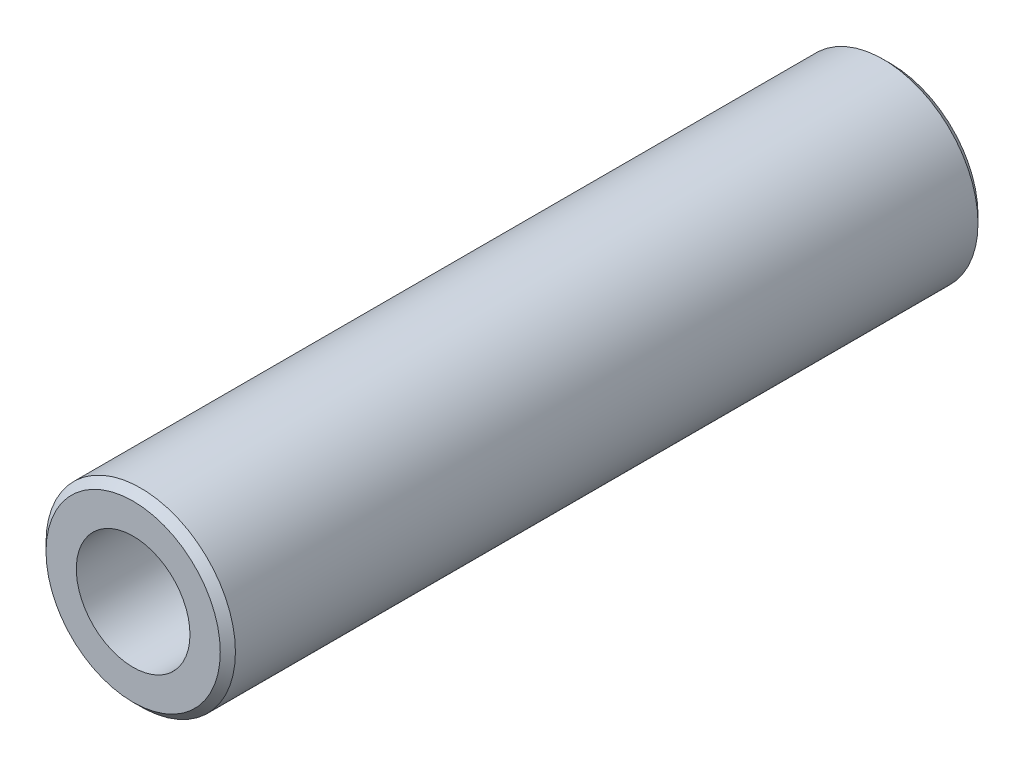
from build123d import *

# Parameters (mm, degrees)
SKETCH1_R           = 6.25
SKETCH1_R_2         = 3.75
EXTRUDE_THIN1_DEPTH = 25
CHAMFER1_SIZE       = 0.5


with BuildPart() as part:
    # Sketch1 → Extrude-Thin1 (new body, symmetric)
    with BuildSketch(Plane.XY):
        Circle(SKETCH1_R)
        Circle(SKETCH1_R_2, mode=Mode.SUBTRACT)
    extrude(amount=EXTRUDE_THIN1_DEPTH, both=True)

    # Chamfer1
    chamfer1_edges = [part.edges().sort_by_distance(p)[0] for p in [
        (-6.25, 0, -25),
        (-6.25, 0, 25),
    ]]
    chamfer(chamfer1_edges, length=CHAMFER1_SIZE)


solid = part.part
